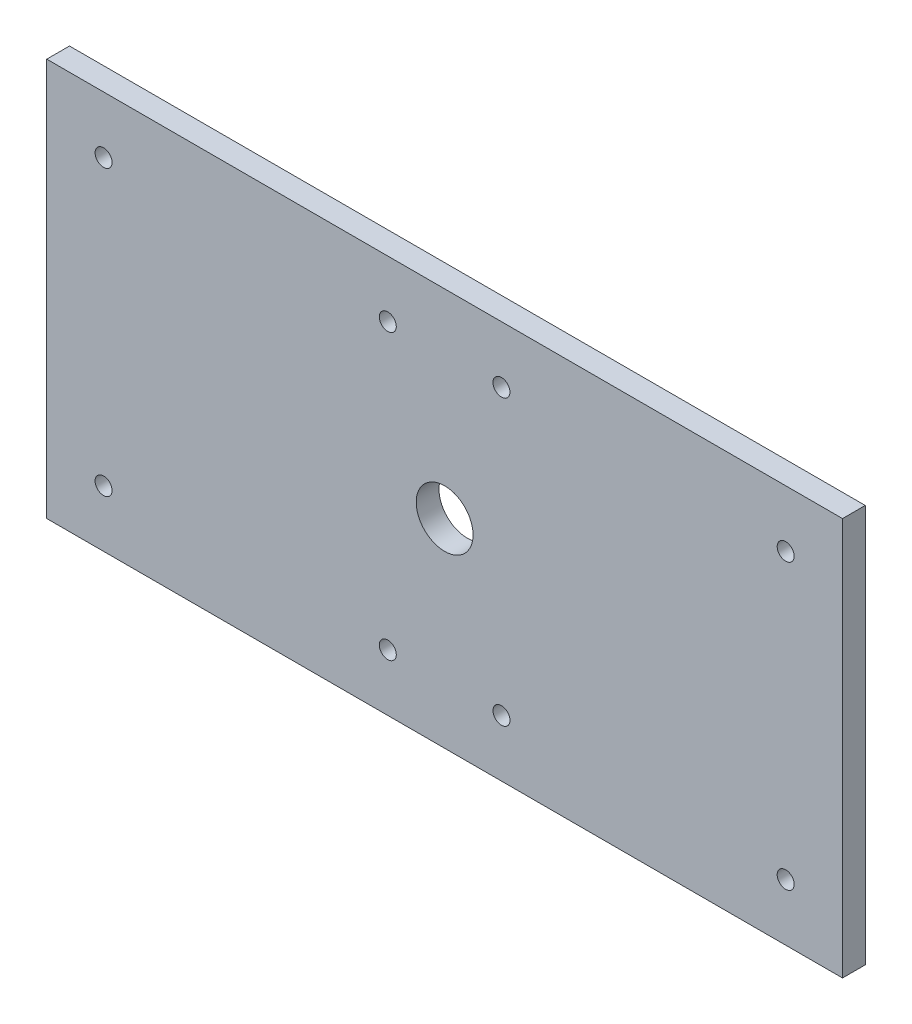
from build123d import *

# Parameters (mm, degrees)
SKETCH1_W             = 177.8
SKETCH1_H             = 88.9
SKETCH1_R             = 6.35
BOSS_EXTRUDE1_DEPTH   = 5.08
F_6_CLEARANCE_HOLE1_D = 3.7973


with BuildPart() as part:
    # Sketch1 → Boss-Extrude1 (new body)
    with BuildSketch(Plane.XY):
        Rectangle(SKETCH1_W, SKETCH1_H)
        Circle(SKETCH1_R, mode=Mode.SUBTRACT)
    extrude(amount=BOSS_EXTRUDE1_DEPTH)

    # #6 Clearance Hole1 (through all)
    with Locations(Plane.XY.offset(5.08)):
        with Locations((76.2, -31.75), (-76.2, 31.75), (-76.2, -31.75), (76.2, 31.75), (12.7, -31.75), (-12.7, 31.75), (-12.7, -31.75), (12.7, 31.75)):
            Hole(F_6_CLEARANCE_HOLE1_D / 2)


solid = part.part
